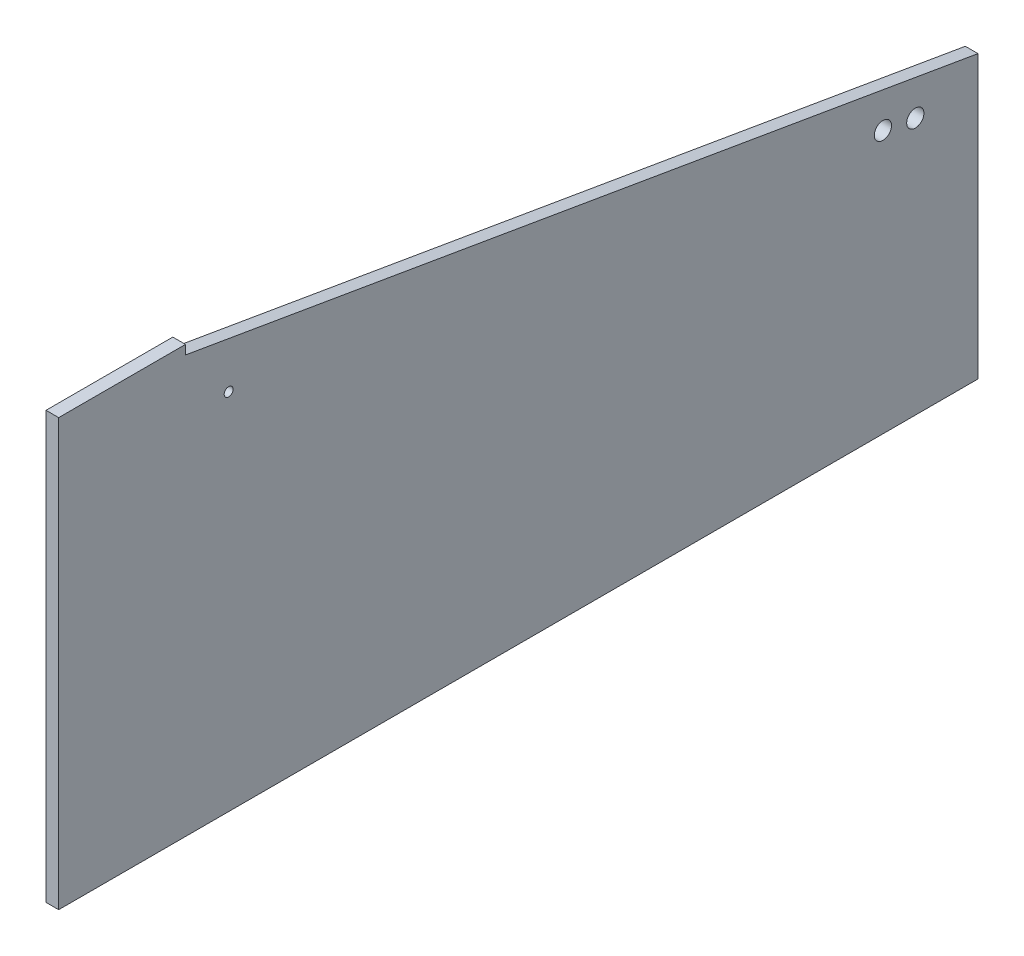
from build123d import *

# Parameters (mm, degrees)
SKETCH1_R           = 12.25
BOSS_EXTRUDE1_DEPTH = 18
SKETCH2_R           = 6.35
CUT_EXTRUDE1_DEPTH  = 40


with BuildPart() as part:
    # Sketch1 → Boss-Extrude1 (new body)
    with BuildSketch(Plane(origin=(0, 0, 0), x_dir=(0, 0, -1), z_dir=(1, 0, 0))):
        Polygon((0, 0), (0, 605), (180, 605), (180, 592), (1305, 400), (1305, 0), align=None)
        with Locations((1216, 365.189333333)):
            Circle(SKETCH1_R, mode=Mode.SUBTRACT)
        with Locations((1170, 373.04)):
            Circle(SKETCH1_R, mode=Mode.SUBTRACT)
    extrude(amount=BOSS_EXTRUDE1_DEPTH)

    # Sketch2 → Cut-Extrude1 (cut)
    with BuildSketch(Plane(origin=(18, 0, 0), x_dir=(0, 0, -1), z_dir=(1, 0, 0))):
        with Locations((241.3, 516.1)):
            Circle(SKETCH2_R)
    extrude(amount=-CUT_EXTRUDE1_DEPTH, mode=Mode.SUBTRACT)


solid = part.part
